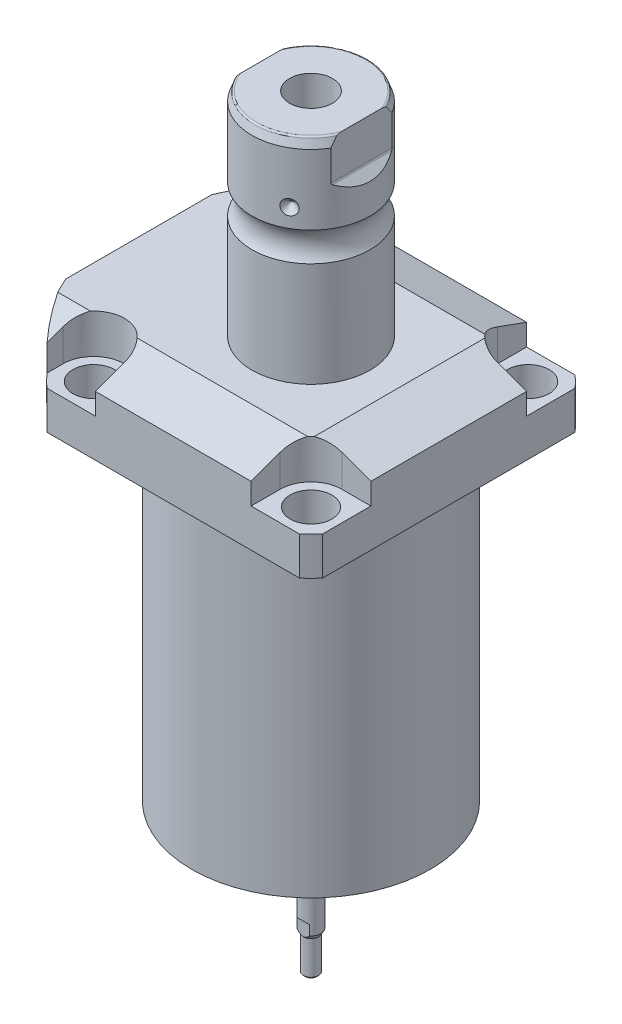
from build123d import *

# Parameters (mm, degrees)
SKETCH1_W               = 88.9
SKETCH1_H               = 99.9998
EXTRUDE1_DEPTH          = 129.794
SKETCH2_OUTSIDE_W       = 139.282
SKETCH2_OUTSIDE_H       = 128.182
SKETCH2_OUTSIDE_R       = 60.325
CUT_EXTRUDE1_DEPTH      = 130.794
SKETCH3_W               = 38.1
SKETCH3_H               = 104.775
FILLET1_R               = 0.381
CUT_EXTRUDE2_DEPTH      = 12.7
CUT_EXTRUDE9_START      = -56.5498
CUT_EXTRUDE9_DEPTH      = 101.9998
CUT_EXTRUDE7_DEPTH      = 45.45
CUT_EXTRUDE7_DEPTH_BACK = 45.45
SKETCH10_R              = 1.1811
SKETCH11_R              = 1.1811
LPATTERN1_COUNT         = 2
LPATTERN1_PITCH         = 25.9588
CUT_EXTRUDE8_DEPTH      = 53.34
SKETCH17_W              = 6.7437
SKETCH17_H              = 12.319
HOLE1_AT_2_COUNT        = 2
HOLE1_AT_2_PITCH        = 70.104
HOLE1_AT_3_COUNT        = 2
HOLE1_AT_3_PITCH        = 99.142027577
HOLE1_AT_4_COUNT        = 2
HOLE1_AT_4_PITCH        = 70.104
CHAMFER1_SIZE           = 0.635
FILLET2_R               = 0.635
CIRPATTERN1_COUNT       = 3
CUT_EXTRUDE10_DEPTH     = 3.81
SKETCH25_W              = 2.7051
SKETCH25_H              = 1.3208
SKETCH26_R              = 1.27
CUT_EXTRUDE11_DEPTH     = 7.62


with BuildPart() as part:
    # Sketch1 → Extrude1 (new body)
    with BuildSketch(Plane.ZX):
        with Locations((0, -5.5499)):
            Rectangle(SKETCH1_W, SKETCH1_H)
    extrude(amount=EXTRUDE1_DEPTH)

    # Sketch2 outside → Cut-Extrude1 (cut, through all)
    with BuildSketch(Plane.XZ):
        with Locations((-5.55, 0)):
            Rectangle(SKETCH2_OUTSIDE_W, SKETCH2_OUTSIDE_H)
        Circle(SKETCH2_OUTSIDE_R, mode=Mode.SUBTRACT)
    extrude(amount=-CUT_EXTRUDE1_DEPTH, mode=Mode.SUBTRACT)

    # Sketch3 → Cut-Revolve1 (revolve, cut)
    with BuildSketch(Plane(origin=(0, 0, 0), x_dir=(0, 0, 1), z_dir=(1, 0, 0))):
        with Locations((57.5437, -52.3875)):
            Rectangle(SKETCH3_W, SKETCH3_H)
    revolve(axis=Axis((0, 93.345, 0), (0, -1, 0)), mode=Mode.SUBTRACT)

    # Fillet1
    fillet1_edges = [part.edges().sort_by_distance(p)[0] for p in [
        (0, 104.775, -38.4937),
    ]]
    fillet(fillet1_edges, radius=FILLET1_R)

    # Sketch4 → Cut-Extrude2 (cut)
    with BuildSketch(Plane(origin=(0, 129.794, 0), x_dir=(-1, 0, 0), z_dir=(0, 1, 0))):
        with BuildLine():
            Line((-25.1206, -44.45), (-25.1206, -35.052))
            ThreePointArc((-25.1206, -35.052), (-28.029439713, -28.029439713), (-35.052, -25.1206))
            Line((-35.052, -25.1206), (-44.45, -25.1206))
            Line((-44.45, -25.1206), (-44.45, -44.45))
            Line((-44.45, -44.45), (-25.1206, -44.45))
        make_face()
        with BuildLine():
            Line((44.9834, -44.45), (25.1206, -44.45))
            Line((25.1206, -44.45), (25.1206, -35.052))
            ThreePointArc((25.1206, -35.052), (35.052, -25.1206), (44.9834, -35.052))
            Line((44.9834, -35.052), (44.9834, -44.45))
        make_face()
        with BuildLine():
            Line((25.1206, 44.45), (25.1206, 35.052))
            ThreePointArc((25.1206, 35.052), (35.052, 25.1206), (44.9834, 35.052))
            Line((44.9834, 35.052), (44.9834, 44.45))
            Line((44.9834, 44.45), (25.1206, 44.45))
        make_face()
        with BuildLine():
            Line((-35.052, 25.1206), (-44.45, 25.1206))
            Line((-44.45, 25.1206), (-44.45, 44.45))
            Line((-44.45, 44.45), (-25.1206, 44.45))
            Line((-25.1206, 44.45), (-25.1206, 35.052))
            ThreePointArc((-25.1206, 35.052), (-28.029439713, 28.029439713), (-35.052, 25.1206))
        make_face()
    extrude(amount=-CUT_EXTRUDE2_DEPTH, mode=Mode.SUBTRACT)

    # Sketch5 → Cut-Extrude9 (cut)
    with BuildSketch(Plane(origin=(0, 0, 0), x_dir=(0, 0, -1), z_dir=(1, 0, 0)).offset(CUT_EXTRUDE9_START)):
        Polygon((-28.575, 129.794), (-44.45, 124.015972531), (-44.45, 129.794), align=None)
    cut_extrude9 = extrude(amount=CUT_EXTRUDE9_DEPTH, mode=Mode.SUBTRACT)

    # Mirror1: Cut-Extrude9 across plane
    add(cut_extrude9.mirror(Plane.XY), mode=Mode.SUBTRACT)

    # Sketch9 → Cut-Extrude7 (cut, two sides)
    with BuildSketch(Plane.XY) as cut_extrude7_sk:
        Polygon((28.575, 129.794), (44.45, 124.015972531), (44.45, 129.794), align=None)
    extrude(amount=CUT_EXTRUDE7_DEPTH, mode=Mode.SUBTRACT)
    extrude(cut_extrude7_sk.sketch, amount=-CUT_EXTRUDE7_DEPTH_BACK, mode=Mode.SUBTRACT)

    # Sketch20 → Cut-Revolve4 (revolve, cut)
    with BuildSketch(Plane(origin=(-41.402, 88.9, -18.1102), x_dir=(0, 1, 0), z_dir=(1, 0, 0)), mode=Mode.PRIVATE) as cut_revolve4_sk:
        Polygon((15.875, 41.9227), (17.3228, 41.9227), (17.3228, 39.4716), (18.3388, 39.4716), (18.3388, 37.465), (29.3116, 37.465), (29.3116, 36.2204), (15.875, 36.2204), align=None)
    cut_revolve4 = revolve(cut_revolve4_sk.sketch.rotate(Axis((-41.402, 81.620304954, 18.1102), (0, 1, 0)), 180), axis=Axis((-41.402, 81.620304954, 18.1102), (0, 1, 0)), mode=Mode.SUBTRACT)  # turned: the seam where the file's is

    # Mirror10: Cut-Revolve4 across plane
    add(cut_revolve4.mirror(Plane.XY), mode=Mode.SUBTRACT)

    # S2D0007 → Cut-Revolve2 (revolve, cut)
    with BuildSketch(Plane(origin=(-55.5498, 101.9048, 12.9794), x_dir=(0, 1, 0), z_dir=(0, 0, 1)), mode=Mode.PRIVATE) as cut_revolve2_sk:
        Polygon((15.875, 0), (26.3525, 0), (26.3525, -0.254), (22.0599, -0.254), (21.517306865, -2.8067), (20.8534, -3.470606865), (20.8534, -14.224), (15.875, -14.224), align=None)
    cut_revolve2 = revolve(cut_revolve2_sk.sketch.rotate(Axis((-40.6146, 117.7798, 12.9794), (-1, 0, 0)), 90), axis=Axis((-40.6146, 117.7798, 12.9794), (-1, 0, 0)), mode=Mode.SUBTRACT)  # turned: the seam where the file's is

    # LPattern1: Cut-Revolve2 ×2
    with Locations(*[(0, 0, -i * LPATTERN1_PITCH) for i in range(1, LPATTERN1_COUNT)]):
        add(cut_revolve2, mode=Mode.SUBTRACT)

    # Sketch15 → Revolve3 (revolve)
    with BuildSketch(Plane(origin=(0, 0, 0), x_dir=(0, -1, 0), z_dir=(1, 0, 0)), mode=Mode.PRIVATE) as revolve3_sk:
        with BuildLine():
            Line((-129.794, 0), (-129.794, 19.05))
            Line((-129.794, 19.05), (-163.46630643, 19.05))
            ThreePointArc((-163.46630643, 19.05), (-168.1734, 17.5006), (-172.88049357, 19.05))
            Line((-172.88049357, 19.05), (-195.4276, 19.05))
            Line((-195.4276, 19.05), (-198.3486, 17.986842946))
            Line((-198.3486, 17.986842946), (-198.3486, 0))
            Line((-198.3486, 0), (-129.794, 0))
        make_face()
    revolve(revolve3_sk.sketch.rotate(Axis((0, 197.63613, 0), (0, -1, 0)), 180), axis=Axis((0, 197.63613, 0), (0, -1, 0)))  # turned: the seam where the file's is

    # Sketch16 → Cut-Extrude8 (cut, symmetric)
    with BuildSketch(Plane(origin=(0, 0, 0), x_dir=(0, -1, 0), z_dir=(0, 0, -1))):
        with BuildLine():
            Line((-198.3486, 19.05), (-182.564369265, 19.05))
            Line((-182.564369265, 19.05), (-185.109784633, 16.504584633))
            ThreePointArc((-185.109784633, 16.504584633), (-185.356995225, 16.339403796), (-185.6486, 16.2814))
            Line((-185.6486, 16.2814), (-198.3486, 16.2814))
            Line((-198.3486, 16.2814), (-198.3486, 19.05))
        make_face()
        with BuildLine():
            Line((-198.3486, -19.05), (-198.3486, -16.2814))
            Line((-198.3486, -16.2814), (-185.6486, -16.2814))
            ThreePointArc((-185.6486, -16.2814), (-185.356995225, -16.339403796), (-185.109784633, -16.504584633))
            Line((-185.109784633, -16.504584633), (-182.564369265, -19.05))
            Line((-182.564369265, -19.05), (-198.3486, -19.05))
        make_face()
    extrude(amount=CUT_EXTRUDE8_DEPTH, both=True, mode=Mode.SUBTRACT)

    # Sketch17 → Hole1 (revolve, cut)
    with BuildSketch(Plane(origin=(35.052, 117.094, -35.052), x_dir=(0, 0, 1), z_dir=(1, 0, 0))):
        with Locations((3.37185, 6.1595)):
            Rectangle(SKETCH17_W, SKETCH17_H)
    hole1 = revolve(axis=Axis((35.052, 7.094, -35.052), (0, 1, 0)), mode=Mode.SUBTRACT)

    # Hole1 at 2: Hole1 ×2
    with Locations(*[(0, 0, i * HOLE1_AT_2_PITCH) for i in range(1, HOLE1_AT_2_COUNT)]):
        add(hole1, mode=Mode.SUBTRACT)

    # Hole1 at 3: Hole1 ×2
    with Locations(*[Vector(-0.707106781, 0, 0.707106781) * (i * HOLE1_AT_3_PITCH) for i in range(1, HOLE1_AT_3_COUNT)]):
        add(hole1, mode=Mode.SUBTRACT)

    # Hole1 at 4: Hole1 ×2
    with Locations(*[(-i * HOLE1_AT_4_PITCH, 0, 0) for i in range(1, HOLE1_AT_4_COUNT)]):
        add(hole1, mode=Mode.SUBTRACT)

    # Chamfer1
    chamfer1_edges = [part.edges().sort_by_distance(p)[0] for p in [
        (-41.402, 107.2388, 19.3548),
        (-41.402, 107.2388, -19.3548),
    ]]
    chamfer(chamfer1_edges, length=CHAMFER1_SIZE)

    # Sketch21 → Cut-Revolve5 (revolve, cut)
    with BuildSketch(Plane.XY, mode=Mode.PRIVATE) as cut_revolve5_sk:
        Polygon((0, 172.9486), (6.9342, 177.115087704), (6.9342, 198.3486), (0, 198.3486), align=None)
    revolve(cut_revolve5_sk.sketch.rotate(Axis((0, 0, 0), (0, 1, 0)), 270), axis=Axis((0, 0, 0), (0, 1, 0)), mode=Mode.SUBTRACT)  # turned: the seam where the file's is

    # Fillet2
    fillet2_edges = [part.edges().sort_by_distance(p)[0] for p in [
        (0, 198.3486, 17.986842946),
        (0, 198.3486, -17.986842946),
    ]]
    fillet(fillet2_edges, radius=FILLET2_R)

    # Sketch22 → Cut-Revolve6 (revolve, cut)
    with BuildSketch(Plane.XY, mode=Mode.PRIVATE) as cut_revolve6_sk:
        Polygon((-19.05, 181.2544), (-16.637, 178.8414), (-19.05, 178.8414), align=None)
    cut_revolve6 = revolve(cut_revolve6_sk.sketch.rotate(Axis((-37.997376206, 178.8414, 0), (1, 0, 0)), 90), axis=Axis((-37.997376206, 178.8414, 0), (1, 0, 0)), mode=Mode.SUBTRACT)  # turned: the seam where the file's is

    # CirPattern1: Cut-Revolve6 ×3 about axis
    cirpattern1_axis = Axis((0, 197.63613, 0), (0, 1, 0))
    for i in range(1, CIRPATTERN1_COUNT):
        add(cut_revolve6.rotate(cirpattern1_axis, i * 360 / CIRPATTERN1_COUNT), mode=Mode.SUBTRACT)

    # Sketch23 → Revolve5 (revolve)
    with BuildSketch(Plane(origin=(0, 0, 0), x_dir=(0, 0, -1), z_dir=(1, 0, 0)), mode=Mode.PRIVATE) as revolve5_sk:
        Polygon((0, 0), (3.175, 0), (3.175, -35.604971375), (2.4384, -36.8808), (2.4384, -47.6758), (1.8034, -48.3108), (0, -48.3108), align=None)
    revolve(revolve5_sk.sketch.rotate(Axis((0, -1000, 0), (0, 1, 0)), 180), axis=Axis((0, -1000, 0), (0, 1, 0)))  # turned: the seam where the file's is

    # Sketch24 → Cut-Extrude10 (cut, symmetric)
    with BuildSketch(Plane(origin=(0, 0, 0), x_dir=(0, 0, -1), z_dir=(1, 0, 0))):
        Polygon((3.175, -31.7627), (2.5019, -32.4358), (2.5019, -48.3108), (3.175, -48.3108), align=None)
        Polygon((-3.175, -48.3108), (-2.5019, -48.3108), (-2.5019, -32.4358), (-3.175, -31.7627), align=None)
    extrude(amount=CUT_EXTRUDE10_DEPTH, both=True, mode=Mode.SUBTRACT)

    # Sketch25 → Cut-Revolve7 (revolve, cut)
    with BuildSketch(Plane(origin=(0, 0, 0), x_dir=(0, 0, -1), z_dir=(1, 0, 0)), mode=Mode.PRIVATE) as cut_revolve7_sk:
        with Locations((12.99845, 0.6604)):
            Rectangle(SKETCH25_W, SKETCH25_H)
    revolve(cut_revolve7_sk.sketch.rotate(Axis((0, -1000, 0), (0, 1, 0)), 218.00100076), axis=Axis((0, -1000, 0), (0, 1, 0)), mode=Mode.SUBTRACT)  # turned: the seam where the file's is

    # Sketch26 → Cut-Extrude11 (cut)
    with BuildSketch(Plane.XZ):
        with Locations(Location((19.431, 0, 0), (0, 0, 270))):  # turned: the seam where the file's is
            Circle(SKETCH26_R)
        with Locations(Location((18.768904731, -5.029112865, 0), (0, 0, 270))):  # turned: the seam where the file's is
            Circle(SKETCH26_R)
        with Locations(Location((-9.7155, 16.827739621, 0), (0, 0, 90))):  # turned: the seam where the file's is
            Circle(SKETCH26_R)
        with Locations(Location((-13.739791865, 13.739791865, 0), (0, 0, 90))):  # turned: the seam where the file's is
            Circle(SKETCH26_R)
        with Locations(Location((-13.739791865, -13.739791865, 0), (0, 0, 270))):  # turned: the seam where the file's is
            Circle(SKETCH26_R)
        with Locations(Location((-9.7155, -16.827739621, 0), (0, 0, 270))):  # turned: the seam where the file's is
            Circle(SKETCH26_R)
    extrude(amount=-CUT_EXTRUDE11_DEPTH, mode=Mode.SUBTRACT)


with BuildPart() as body_2:
    # Sketch10 → Revolve4 (revolve)
    with BuildSketch(Plane(origin=(-41.402, 88.9, -18.1102), x_dir=(0, 1, 0), z_dir=(1, 0, 0))):
        with Locations((16.1417, 4.5212)):
            Circle(SKETCH10_R)
    revolve(axis=Axis((-41.402, 87.86749, -18.1102), (0, 1, 0)))


with BuildPart() as body_3:
    # Sketch11 → Revolve2 (revolve)
    with BuildSketch(Plane(origin=(-41.402, 88.9, 18.1102), x_dir=(0, 1, 0), z_dir=(1, 0, 0)), mode=Mode.PRIVATE) as revolve2_sk:
        with Locations((16.1417, 4.5212)):
            Circle(SKETCH11_R)
    revolve(revolve2_sk.sketch.rotate(Axis((-41.402, 87.86749, 18.1102), (0, 1, 0)), 180), axis=Axis((-41.402, 87.86749, 18.1102), (0, 1, 0)))  # turned: the seam where the file's is


solid = Compound([part.part, body_2.part, body_3.part])
